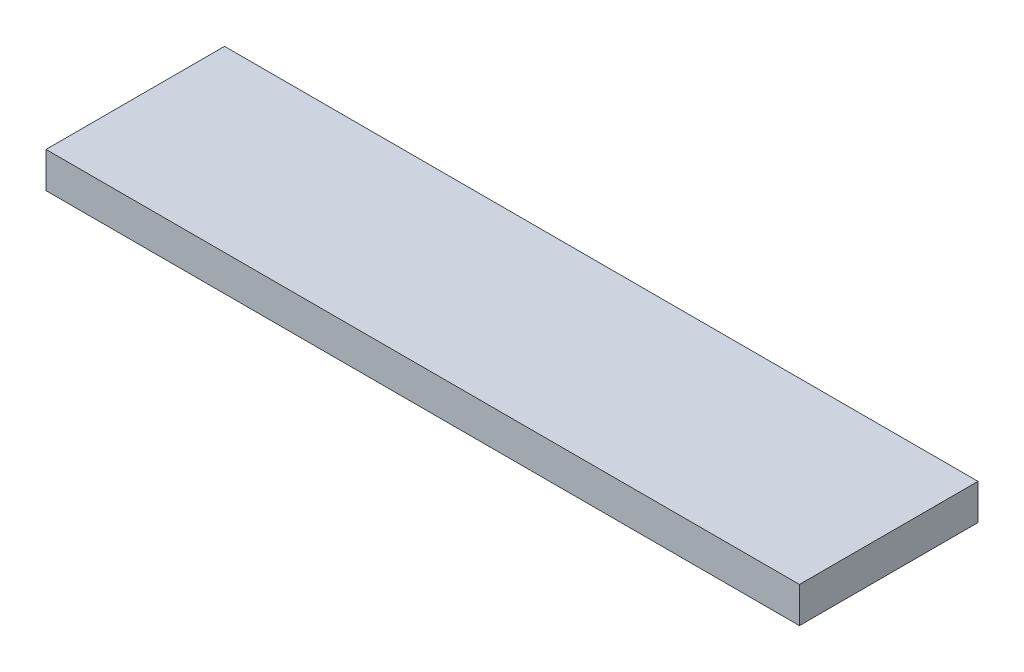
from build123d import *

# Parameters (mm, degrees)
SKETCH1_W           = 63.3
SKETCH1_H           = 15
BOSS_EXTRUDE1_DEPTH = 3


with BuildPart() as part:
    # Sketch1 → Boss-Extrude1 (new body)
    with BuildSketch(Plane(origin=(0, 0, 0), x_dir=(1, 0, 0), z_dir=(0, 1, 0))):
        Rectangle(SKETCH1_W, SKETCH1_H)
    extrude(amount=BOSS_EXTRUDE1_DEPTH)


solid = part.part
